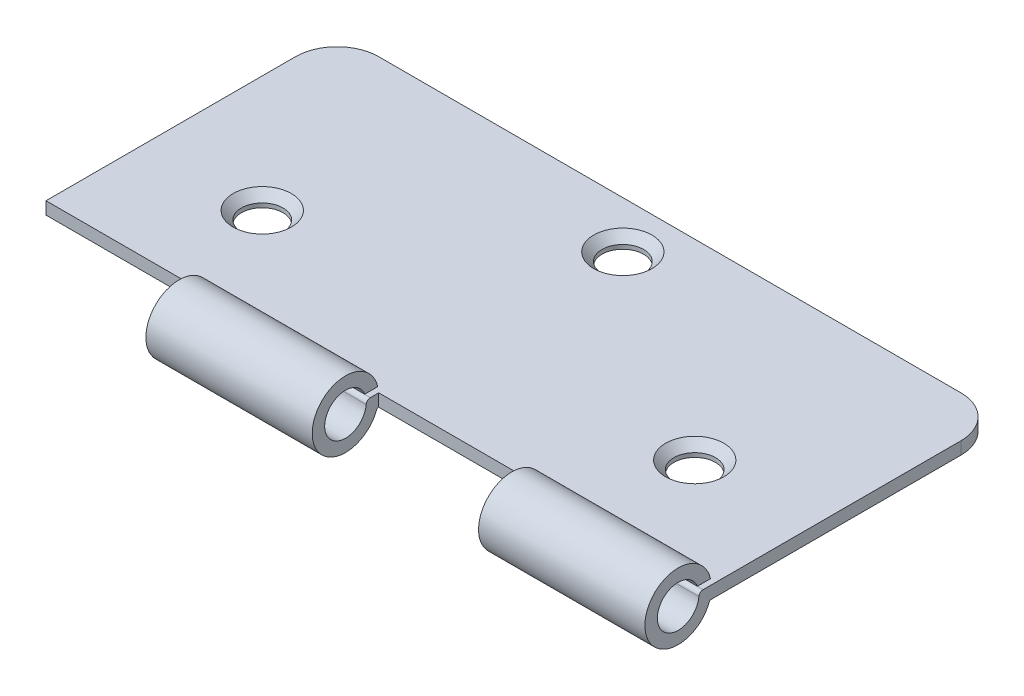
from build123d import *

# Parameters (mm, degrees)
BOSS_EXTRUDE1_DEPTH = 1.5
BOSS_EXTRUDE2_DEPTH = 20
LPATTERN1_COUNT     = 2
LPATTERN1_PITCH     = 40
SKETCH3_R           = 2.5
CUT_EXTRUDE1_DEPTH  = 5.238595513
CHAMFER1_SIZE       = 1


with BuildPart() as part:
    # Sketch1 → Boss-Extrude1 (new body)
    with BuildSketch(Plane(origin=(0, 0, 0), x_dir=(1, 0, 0), z_dir=(0, 1, 0))):
        with BuildLine():
            Line((-40, -17.5), (40, -17.5))
            Line((40, -17.5), (40, 12.5))
            ThreePointArc((40, 12.5), (38.535533906, 16.035533906), (35, 17.5))
            Line((35, 17.5), (-35, 17.5))
            ThreePointArc((-35, 17.5), (-38.535533906, 16.035533906), (-40, 12.5))
            Line((-40, 12.5), (-40, -17.5))
        make_face()
    extrude(amount=BOSS_EXTRUDE1_DEPTH)

    # Sketch2 → Boss-Extrude2 (add)
    with BuildSketch(Plane(origin=(40, 0, 0), x_dir=(0, 0, -1), z_dir=(1, 0, 0))):
        with BuildLine():
            Line((-17.5, 1.5), (-18.504288099, 1.5))
            ThreePointArc((-18.504288099, 1.5), (-18.842087072, 1.368635123), (-19.002386363, 1.043567414))
            ThreePointArc((-19.002386363, 1.043567414), (-23.96573551, 0.894016186), (-19.173284523, 2.193867665))
            Line((-19.173284523, 2.193867665), (-17.603081746, 2.193867665))
            ThreePointArc((-17.603081746, 2.193867665), (-25.485667036, 1.501473584), (-17.742830435, -0.13040931))
            ThreePointArc((-17.742830435, -0.13040931), (-17.669524968, -0.035807829), (-17.555328072, 0))
            Line((-17.555328072, 0), (-17.5, 0))
            Line((-17.5, 0), (-17.5, 1.5))
        make_face()
    boss_extrude2 = extrude(amount=-BOSS_EXTRUDE2_DEPTH)

    # LPattern1: Boss-Extrude2 ×2
    with Locations(*[(-i * LPATTERN1_PITCH, 0, 0) for i in range(1, LPATTERN1_COUNT)]):
        add(boss_extrude2)

    # Sketch3 → Cut-Extrude1 (cut, through all)
    with BuildSketch(Plane(origin=(0, 1.5, 0), x_dir=(1, 0, 0), z_dir=(0, 1, 0))):
        with Locations((-26, -5.5)):
            Circle(SKETCH3_R)
        with Locations((26, -5.5)):
            Circle(SKETCH3_R)
        with Locations((0, 11.85566874)):
            Circle(SKETCH3_R)
    extrude(amount=-CUT_EXTRUDE1_DEPTH, mode=Mode.SUBTRACT)

    # Chamfer1
    chamfer1_edges = [part.edges().sort_by_distance(p)[0] for p in [
        (-28.5, 1.5, 5.5),
        (23.5, 1.5, 5.5),
        (-2.5, 1.5, -11.85566874),
    ]]
    chamfer(chamfer1_edges, length=CHAMFER1_SIZE)


solid = part.part
